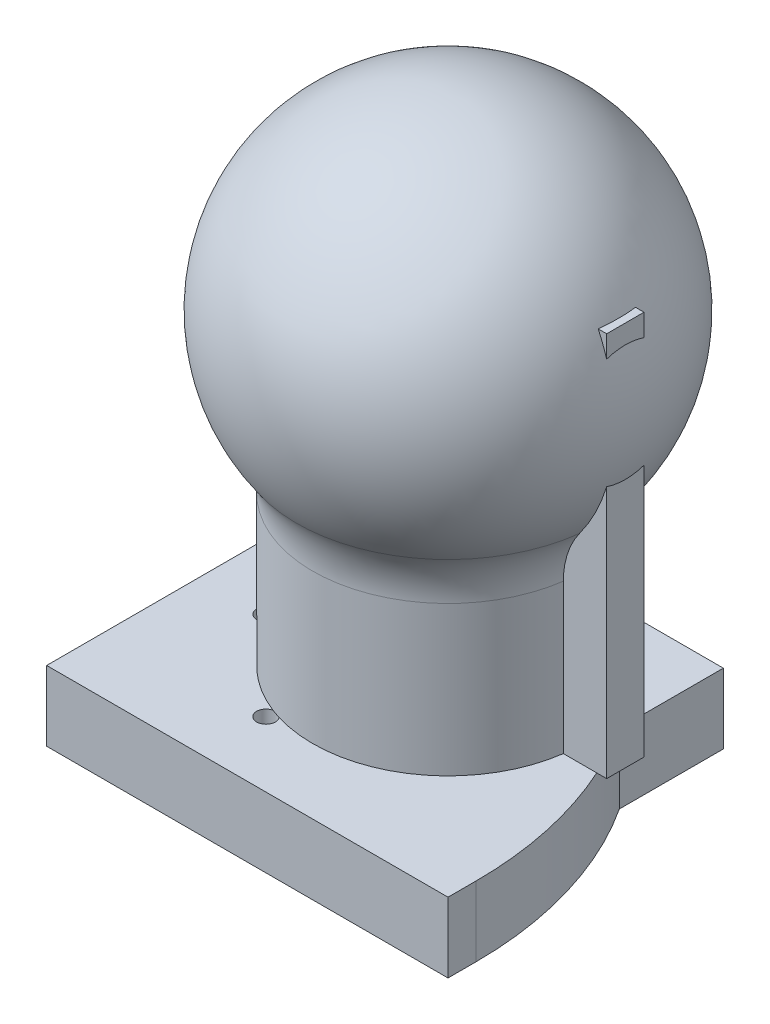
from build123d import *

# Parameters (mm, degrees)
SKETCH1_R           = 29
BOSS_EXTRUDE1_DEPTH = 32
SKETCH3_W           = 8
SKETCH3_H           = 82.55
BOSS_EXTRUDE2_DEPTH = 38
SKETCH5_W           = 58
SKETCH5_H           = 15
BOSS_EXTRUDE3_DEPTH = 30
BOSS_EXTRUDE4_DEPTH = 15
SKETCH7_R           = 2
CUT_EXTRUDE2_DEPTH  = 16


with BuildPart() as part:
    # Sketch1 → Boss-Extrude1 (new body)
    with BuildSketch(Plane(origin=(0, 0, 0), x_dir=(1, 0, 0), z_dir=(0, 1, 0))):
        Circle(SKETCH1_R)
    extrude(amount=BOSS_EXTRUDE1_DEPTH)

    # Sketch2 → Revolve1 (revolve)
    with BuildSketch(Plane.XY):
        with BuildLine():
            Line((-29, 32), (0, 32))
            Line((0, 32), (0, 106))
            ThreePointArc((0, 106), (-35.617387288, 84.204442392), (-32.419733751, 42.570086139))
            ThreePointArc((-32.419733751, 42.570086139), (-29.876205733, 37.554756969), (-29, 32))
        make_face()
    revolve(axis=Axis((0, 32, 0), (0, 1, 0)))

    # Sketch3 → Boss-Extrude2 (add)
    with BuildSketch(Plane(origin=(0, 0, 0), x_dir=(0, 0, -1), z_dir=(1, 0, 0))):
        with Locations((0, 41.275)):
            Rectangle(SKETCH3_W, SKETCH3_H)
    extrude(amount=BOSS_EXTRUDE2_DEPTH)

    # Sketch5 → Boss-Extrude3 (add, symmetric)
    with BuildSketch(Plane(origin=(0, 0, 0), x_dir=(0, 0, -1), z_dir=(1, 0, 0))):
        with Locations((0, -7.5)):
            Rectangle(SKETCH5_W, SKETCH5_H)
    extrude(amount=BOSS_EXTRUDE3_DEPTH, both=True)

    # Sketch6 → Boss-Extrude4 (add)
    with BuildSketch(Plane.XZ.offset(15)):
        with BuildLine():
            Line((-37, -43), (-43, -43))
            Line((-43, -43), (-43, 43))
            Line((-43, 43), (43, 43))
            Line((43, 43), (43, 37))
            ThreePointArc((43, 37), (19.568542495, -19.568542495), (-37, -43))
        make_face()
    extrude(amount=-BOSS_EXTRUDE4_DEPTH)

    # Sketch7 → Cut-Extrude2 (cut, through all)
    with BuildSketch(Plane(origin=(0, 0, 0), x_dir=(1, 0, 0), z_dir=(0, 1, 0))):
        with Locations((-29, -10)):
            Circle(SKETCH7_R)
        with Locations((-10, -29)):
            Circle(SKETCH7_R)
    extrude(amount=-CUT_EXTRUDE2_DEPTH, mode=Mode.SUBTRACT)


solid = part.part
